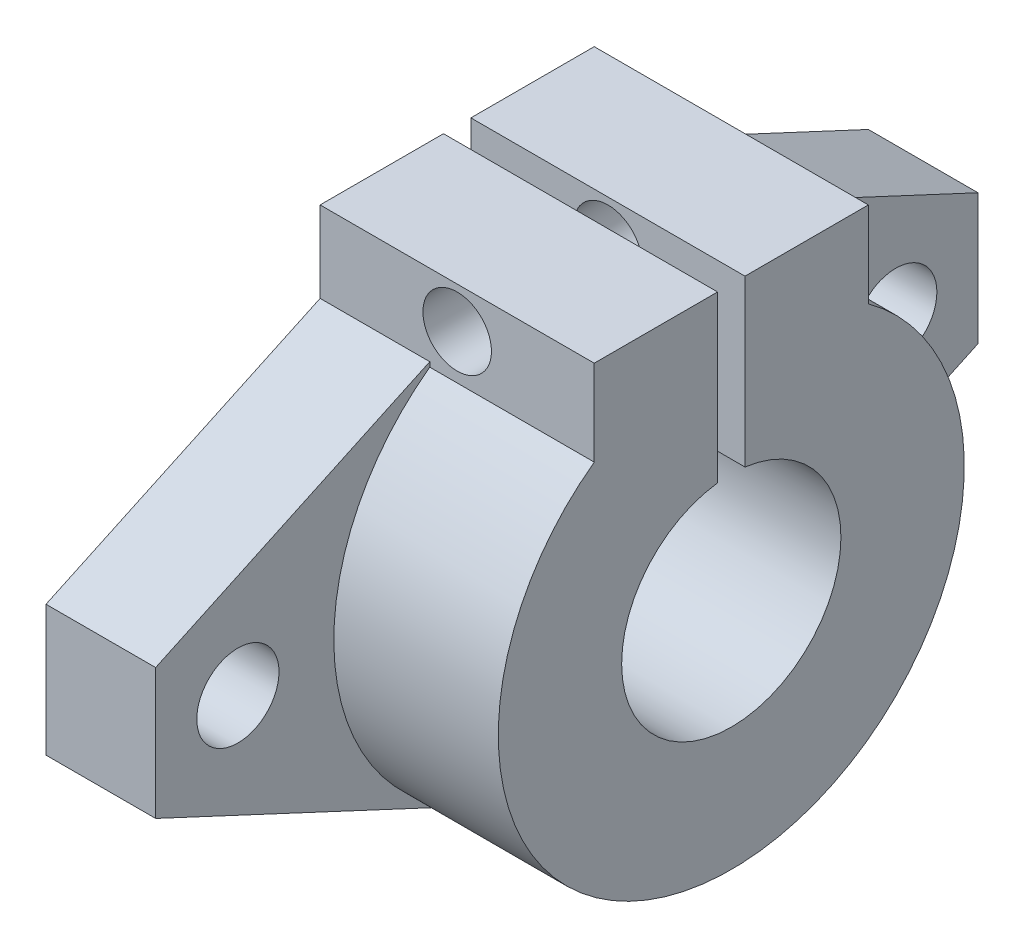
from build123d import *

# Parameters (mm, degrees)
SKETCH_1_R          = 3
EXTRUDE_1_DEPTH     = 8
EXTRUDE_1_2_DEPTH   = 8
SKETCH_1_3_R        = 8
EXTRUDE_2_DEPTH     = 20
EXTRUDE_3_REACH     = 53.662
SKETCH_2_W          = 20
SKETCH_2_H          = 20
SKETCH_3_W          = 20
SKETCH_3_H          = 2
CUT_EXTRUDE_1_DEPTH = 20
SKETCH_4_R          = 2.5
CUT_EXTRUDE_2_DEPTH = 49.989794856


with BuildPart() as part:
    # 草图1 → 凸台-拉伸1 (new body)
    with BuildSketch(Plane(origin=(0, 0, 0), x_dir=(0, 0, -1), z_dir=(1, 0, 0))):
        with BuildLine():
            Line((-7.18451045, 15.40723238), (-30, 4.768194878))
            Line((-30, 4.768194878), (-30, -4.768194878))
            Line((-30, -4.768194878), (-7.18451045, -15.40723238))
            ThreePointArc((-7.18451045, -15.40723238), (-17, 0), (-7.18451045, 15.40723238))
        make_face()
        with Locations((-24, 0)):
            Circle(SKETCH_1_R, mode=Mode.SUBTRACT)
    extrude(amount=EXTRUDE_1_DEPTH)



with BuildPart() as body_2:
    # 草图1 → Extrude 1 2 (new body)
    with BuildSketch(Plane(origin=(0, 0, 0), x_dir=(0, 0, -1), z_dir=(1, 0, 0))):
        with BuildLine():
            Line((30, 4.768194878), (7.18451045, 15.40723238))
            ThreePointArc((7.18451045, 15.40723238), (17, 0), (7.18451045, -15.40723238))
            Line((7.18451045, -15.40723238), (30, -4.768194878))
            Line((30, -4.768194878), (30, 4.768194878))
        make_face()
        with Locations((24, 0)):
            Circle(SKETCH_1_R, mode=Mode.SUBTRACT)
    extrude(amount=EXTRUDE_1_2_DEPTH)


with BuildPart() as part_1:
    add(part.part)

    add(body_2.part)  # 凸台-拉伸2 merges body 2
    # 草图1<3> → 凸台-拉伸2 (add)
    with BuildSketch(Plane(origin=(0, 0, 0), x_dir=(0, 0, -1), z_dir=(1, 0, 0))):
        with BuildLine():
            ThreePointArc((7.18451045, 15.40723238), (0, 17), (-7.18451045, 15.40723238))
            ThreePointArc((-7.18451045, 15.40723238), (-17, 0), (-7.18451045, -15.40723238))
            ThreePointArc((-7.18451045, -15.40723238), (0, -17), (7.18451045, -15.40723238))
            ThreePointArc((7.18451045, -15.40723238), (14.337654579, -9.134093342), (17, 0))
            ThreePointArc((17, 0), (14.337654579, 9.134093342), (7.18451045, 15.40723238))
        make_face()
        Circle(SKETCH_1_3_R, mode=Mode.SUBTRACT)
    extrude(amount=EXTRUDE_2_DEPTH)

    # 草图2 → 凸台-拉伸3 (add, up to next)
    with BuildSketch(Plane(origin=(0, 20, 0), x_dir=(1, 0, 0), z_dir=(0, 1, 0)), mode=Mode.PRIVATE) as extrude_3_sk1:
        with Locations((10, 0)):
            Rectangle(SKETCH_2_W, SKETCH_2_H)
    extrude_3_tool1 = extrude(extrude_3_sk1.sketch, amount=-EXTRUDE_3_REACH, mode=Mode.PRIVATE) - part_1.part
    add(extrude_3_tool1.solids().sort_by_distance((10, 20, 0))[0])

    # 草图3 → 切除-拉伸1 (cut)
    with BuildSketch(Plane(origin=(0, 20, 0), x_dir=(1, 0, 0), z_dir=(0, 1, 0))):
        with Locations((10, 0)):
            Rectangle(SKETCH_3_W, SKETCH_3_H)
    extrude(amount=-CUT_EXTRUDE_1_DEPTH, mode=Mode.SUBTRACT)

    # 草图4 → 切除-拉伸2 (cut, through all)
    with BuildSketch(Plane.XY.offset(10)):
        with Locations((10, 17)):
            Circle(SKETCH_4_R)
    extrude(amount=-CUT_EXTRUDE_2_DEPTH, mode=Mode.SUBTRACT)


solid = part_1.part
